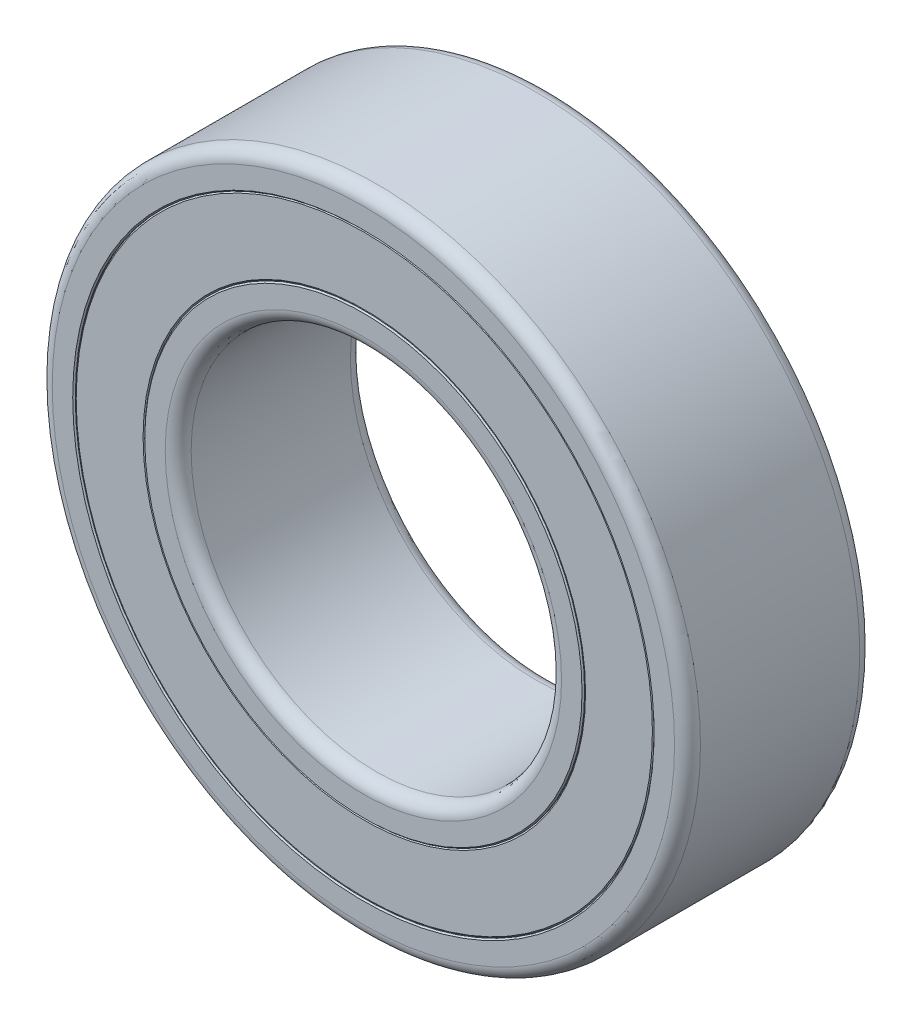
from build123d import *

# Parameters (mm, degrees)
SKETCH_R_INNER_BODY_W   = 4
SKETCH_R_INNER_BODY_H   = 0.75
FILLET_INNER_BODY_R     = 0.28
CHAMFER_INNER_BODY_SIZE = 0.028
SKETCH_R_OUTER_BODY_W   = 4
SKETCH_R_OUTER_BODY_H   = 0.75
FILLET_OUTER_BODY_R     = 0.28
CHAMFER_OUTER_BODY_SIZE = 0.028
SKETCH_R_SEAL_FACES_W   = 3.96
SKETCH_R_SEAL_FACES_H   = 1.5
CHAMFER_SEALS_SIZE      = 0.028


with BuildPart() as part:
    # Sketch R, INNER BODY → Revolve INNER BODY (revolve)
    with BuildSketch(Plane(origin=(0, 0, 0), x_dir=(0, 0, -1), z_dir=(1, 0, 0))):
        with Locations((0, 4.375)):
            Rectangle(SKETCH_R_INNER_BODY_W, SKETCH_R_INNER_BODY_H)
    revolve(axis=Axis((0, 0, 17.5), (0, 0, -1)))

    # Fillet INNER BODY
    fillet_inner_body_edges = [part.edges().sort_by_distance(p)[0] for p in [
        (0, -4, -2),
        (0, -4, 2),
    ]]
    fillet(fillet_inner_body_edges, radius=FILLET_INNER_BODY_R)

    # Chamfer INNER BODY
    chamfer_inner_body_edges = [part.edges().sort_by_distance(p)[0] for p in [
        (0, -4.75, 2),
        (0, -4.75, -2),
    ]]
    chamfer(chamfer_inner_body_edges, length=CHAMFER_INNER_BODY_SIZE)


with BuildPart() as body_2:
    # Sketch R, OUTER BODY → Revolve OUTER BODY (revolve)
    with BuildSketch(Plane(origin=(0, 0, 0), x_dir=(0, 0, -1), z_dir=(1, 0, 0))):
        with Locations((0, 6.625)):
            Rectangle(SKETCH_R_OUTER_BODY_W, SKETCH_R_OUTER_BODY_H)
    revolve(axis=Axis((0, 0, 17.5), (0, 0, -1)))

    # Fillet OUTER BODY
    fillet_outer_body_edges = [body_2.edges().sort_by_distance(p)[0] for p in [
        (0, -7, 2),
        (0, -7, -2),
    ]]
    fillet(fillet_outer_body_edges, radius=FILLET_OUTER_BODY_R)

    # Chamfer OUTER BODY
    chamfer_outer_body_edges = [body_2.edges().sort_by_distance(p)[0] for p in [
        (0, -6.25, -2),
        (0, -6.25, 2),
    ]]
    chamfer(chamfer_outer_body_edges, length=CHAMFER_OUTER_BODY_SIZE)


with BuildPart() as body_3:
    # Sketch R, SEAL FACES → Revolve SEALS (revolve)
    with BuildSketch(Plane(origin=(0, 0, 0), x_dir=(0, 0, -1), z_dir=(1, 0, 0))):
        with Locations((0, 5.5)):
            Rectangle(SKETCH_R_SEAL_FACES_W, SKETCH_R_SEAL_FACES_H)
    revolve(axis=Axis((0, 0, 17.5), (0, 0, -1)))

    # Chamfer SEALS
    chamfer_seals_edges = [body_3.edges().sort_by_distance(p)[0] for p in [
        (0, -4.75, -1.98),
        (0, -4.75, 1.98),
        (0, -6.25, 1.98),
        (0, -6.25, -1.98),
    ]]
    chamfer(chamfer_seals_edges, length=CHAMFER_SEALS_SIZE)


solid = Compound([part.part, body_2.part, body_3.part])
